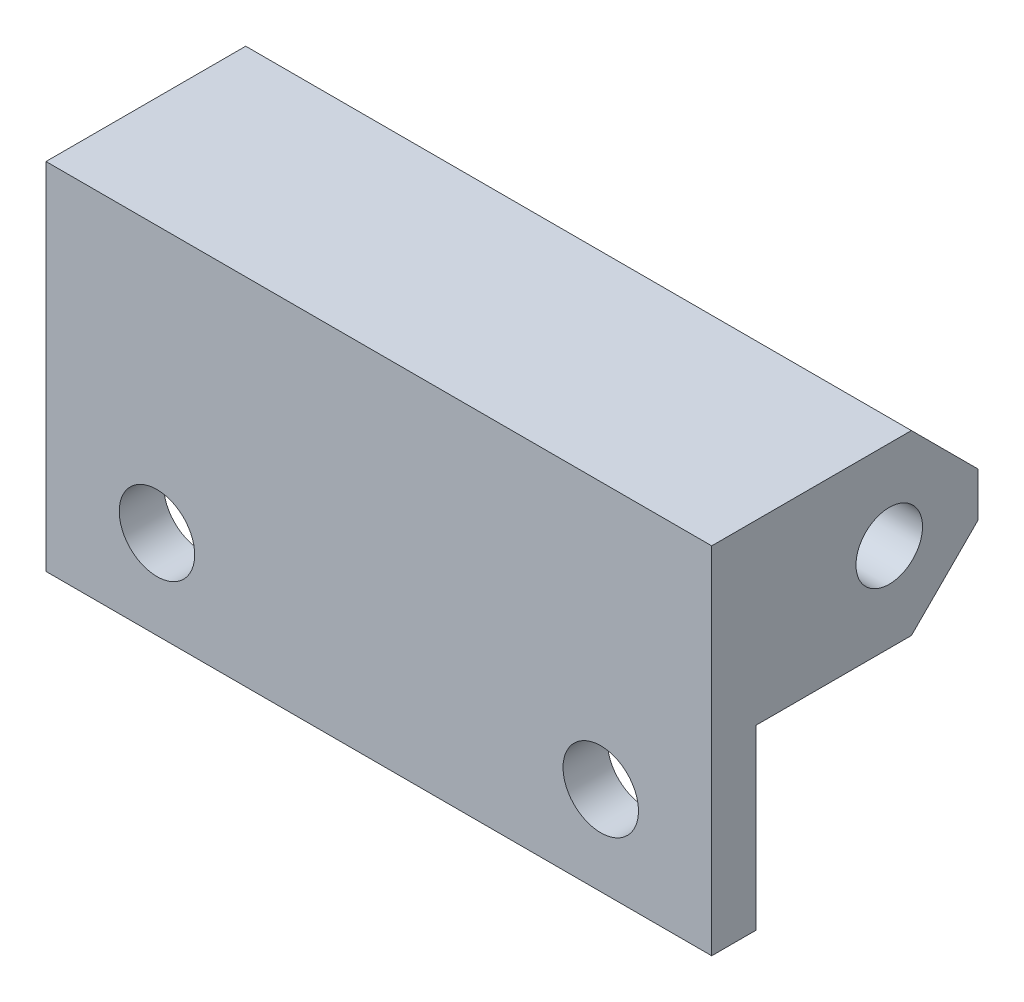
from build123d import *

# Parameters (mm, degrees)
BOSS_EXTRUDE1_DEPTH     = 15
M3_CLEARANCE_HOLE1_D    = 3.4
SKETCH4_R               = 1.5
CUT_EXTRUDE1_DEPTH      = 1
CUT_EXTRUDE1_DEPTH_BACK = 31


with BuildPart() as part:
    # Sketch1 → Boss-Extrude1 (new body, symmetric)
    with BuildSketch(Plane(origin=(0, 0, 0), x_dir=(0, 0, -1), z_dir=(1, 0, 0))):
        Polygon((-8, 8), (0, 8), (1, 8), (4, 5), (4, 3), (1, 0), (0, 0), (-6, 0), (-6, -8), (-8, -8), align=None)
    extrude(amount=BOSS_EXTRUDE1_DEPTH, both=True)

    # M3 Clearance Hole1 (through all)
    with Locations(Plane(origin=(0, 0, 6), x_dir=(-1, 0, 0), z_dir=(0, 0, -1))):
        with Locations((-10, -4), (10, -4)):
            Hole(M3_CLEARANCE_HOLE1_D / 2)

    # Sketch4 → Cut-Extrude1 (cut, two sides)
    with BuildSketch(Plane(origin=(15, 0, 0), x_dir=(0, 0, -1), z_dir=(1, 0, 0))) as cut_extrude1_sk:
        with Locations((0, 4)):
            Circle(SKETCH4_R)
    extrude(amount=CUT_EXTRUDE1_DEPTH, mode=Mode.SUBTRACT)
    extrude(cut_extrude1_sk.sketch, amount=-CUT_EXTRUDE1_DEPTH_BACK, mode=Mode.SUBTRACT)


solid = part.part
